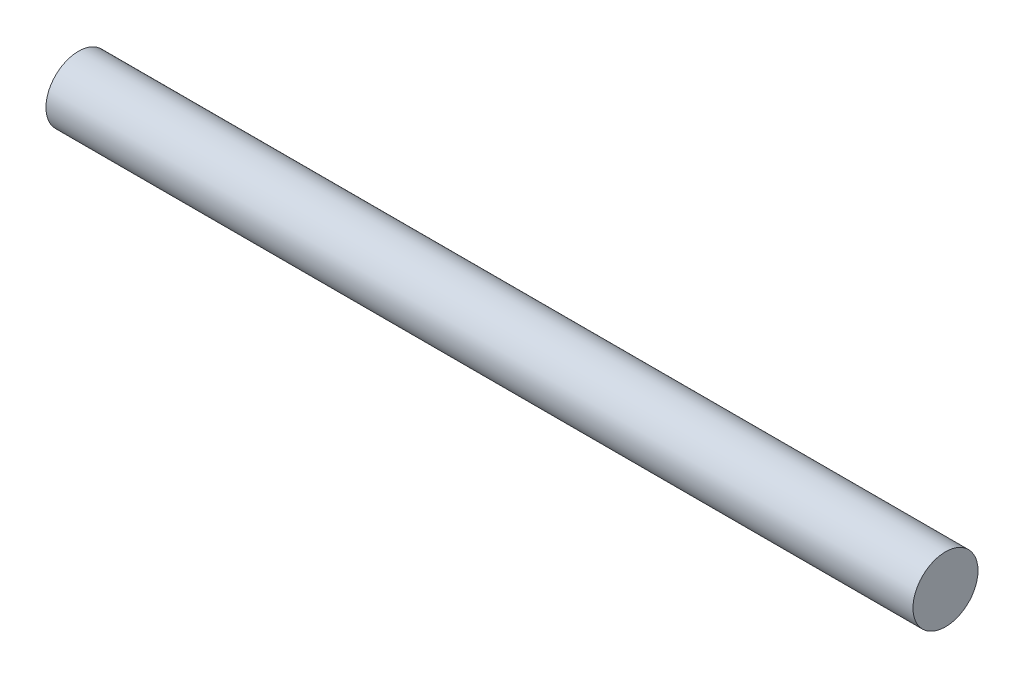
from build123d import *

# Parameters (mm, degrees)
SKETCH1_R           = 4.7625
BOSS_EXTRUDE1_DEPTH = 127


with BuildPart() as part:
    # Sketch1 → Boss-Extrude1 (new body)
    with BuildSketch(Plane(origin=(0, 0, 0), x_dir=(0, 0, -1), z_dir=(1, 0, 0))):
        Circle(SKETCH1_R)
    extrude(amount=BOSS_EXTRUDE1_DEPTH)


solid = part.part
